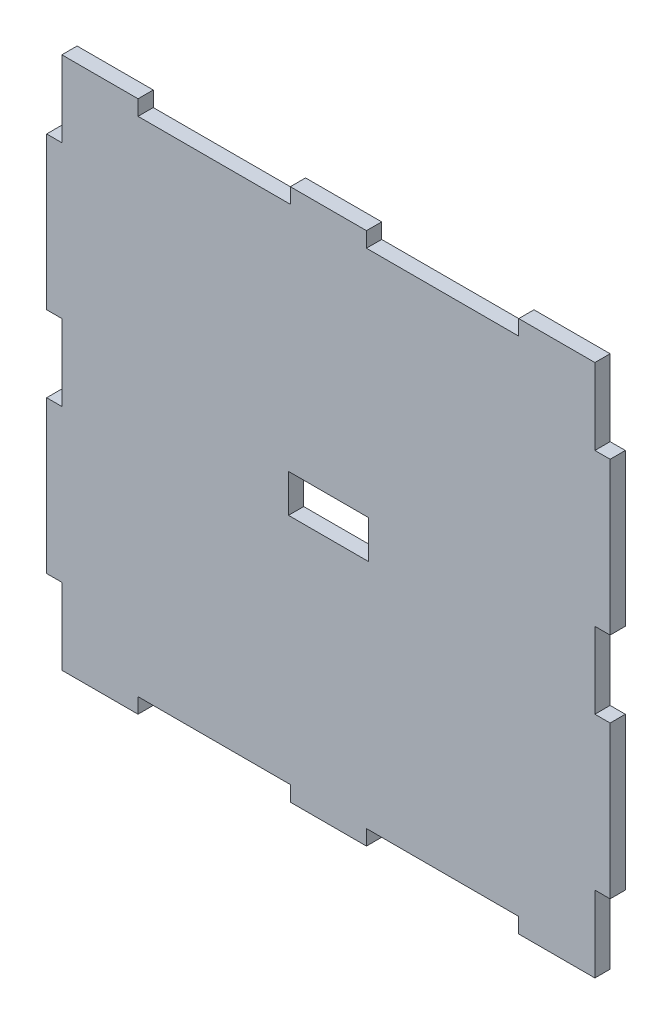
from build123d import *

# Parameters (mm, degrees)
SKETCH1_W           = 70
SKETCH1_H           = 70
BOSS_EXTRUDE1_DEPTH = 2
SKETCH2_W           = 2
SKETCH2_H           = 20
BOSS_EXTRUDE2_DEPTH = 2
SKETCH3_W           = 20
SKETCH3_H           = 2
CUT_EXTRUDE1_DEPTH  = 2
SKETCH4_W           = 10.48
SKETCH4_H           = 5
CUT_EXTRUDE2_DEPTH  = 10


with BuildPart() as part:
    # Sketch1 → Boss-Extrude1 (new body)
    with BuildSketch(Plane.XY):
        Rectangle(SKETCH1_W, SKETCH1_H)
    extrude(amount=-BOSS_EXTRUDE1_DEPTH)

    # Sketch2 → Boss-Extrude2 (add)
    with BuildSketch(Plane.XY):
        with Locations((-36, 15)):
            Rectangle(SKETCH2_W, SKETCH2_H)
        with Locations((-36, -15)):
            Rectangle(SKETCH2_W, SKETCH2_H)
        with Locations((36, -15)):
            Rectangle(SKETCH2_W, SKETCH2_H)
        with Locations((36, 15)):
            Rectangle(SKETCH2_W, SKETCH2_H)
    extrude(amount=-BOSS_EXTRUDE2_DEPTH)

    # Sketch3 → Cut-Extrude1 (cut)
    with BuildSketch(Plane.XY):
        with Locations((-15, 34)):
            Rectangle(SKETCH3_W, SKETCH3_H)
        with Locations((15, 34)):
            Rectangle(SKETCH3_W, SKETCH3_H)
        with Locations((-15, -34)):
            Rectangle(SKETCH3_W, SKETCH3_H)
        with Locations((15, -34)):
            Rectangle(SKETCH3_W, SKETCH3_H)
    extrude(amount=-CUT_EXTRUDE1_DEPTH, mode=Mode.SUBTRACT)

    # Sketch4 → Cut-Extrude2 (cut)
    with BuildSketch(Plane.XY):
        Rectangle(SKETCH4_W, SKETCH4_H)
    extrude(amount=-CUT_EXTRUDE2_DEPTH, mode=Mode.SUBTRACT)


solid = part.part
